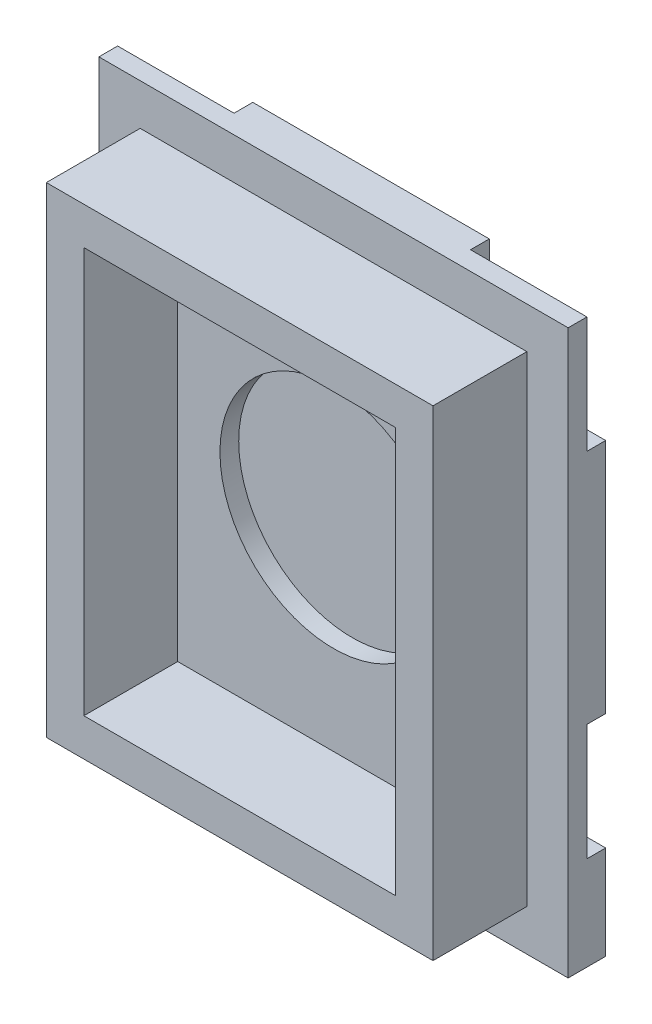
from build123d import *

# Parameters (mm, degrees)
SKETCH_1_W          = 25
SKETCH_1_H          = 30
EXTRUDE_1_DEPTH     = 2
SKETCH_2_W          = 20.6
SKETCH_2_H          = 25.6
EXTRUDE_2_DEPTH     = 5
SKETCH_3_W          = 16.6
SKETCH_3_H          = 21.6
CUT_EXTRUDE_1_DEPTH = 5
SKETCH_4_W          = 6.2
SKETCH_4_H          = 6.2
CUT_EXTRUDE_2_DEPTH = 1
SKETCH_5_R          = 6.05
CUT_EXTRUDE_3_DEPTH = 1


with BuildPart() as part:
    # ｽｹｯﾁ1 → ﾎﾞｽ - 押し出し1 (new body)
    with BuildSketch(Plane.XY):
        with Locations((-24.237274581, 24.707142857)):
            Rectangle(SKETCH_1_W, SKETCH_1_H)
    extrude(amount=EXTRUDE_1_DEPTH)

    # ｽｹｯﾁ2 → ﾎﾞｽ - 押し出し2 (add)
    with BuildSketch(Plane.XY.offset(2)):
        with Locations((-24.237274581, 24.707142857)):
            Rectangle(SKETCH_2_W, SKETCH_2_H)
    extrude(amount=EXTRUDE_2_DEPTH)

    # ｽｹｯﾁ3 → ｶｯﾄ - 押し出し1 (cut)
    with BuildSketch(Plane.XY.offset(7)):
        with Locations((-24.237274581, 24.707142857)):
            Rectangle(SKETCH_3_W, SKETCH_3_H)
    extrude(amount=-CUT_EXTRUDE_1_DEPTH, mode=Mode.SUBTRACT)

    # ｽｹｯﾁ4 → ｶｯﾄ - 押し出し2 (cut)
    with BuildSketch(Plane(origin=(0, 0, 0), x_dir=(-1, 0, 0), z_dir=(0, 0, -1))):
        with Locations((14.837274581, 36.607142857)):
            Rectangle(SKETCH_4_W, SKETCH_4_H)
        with Locations((33.637274581, 36.607142857)):
            Rectangle(SKETCH_4_W, SKETCH_4_H)
        with Locations((33.637274581, 17.807142857)):
            Rectangle(SKETCH_4_W, SKETCH_4_H)
        with Locations((14.837274581, 17.807142857)):
            Rectangle(SKETCH_4_W, SKETCH_4_H)
    extrude(amount=-CUT_EXTRUDE_2_DEPTH, mode=Mode.SUBTRACT)

    # ｽｹｯﾁ5 → ｶｯﾄ - 押し出し3 (cut)
    with BuildSketch(Plane.XY.offset(2)):
        with Locations((-24.237274581, 24.707142857)):
            Circle(SKETCH_5_R)
    extrude(amount=-CUT_EXTRUDE_3_DEPTH, mode=Mode.SUBTRACT)


solid = part.part
